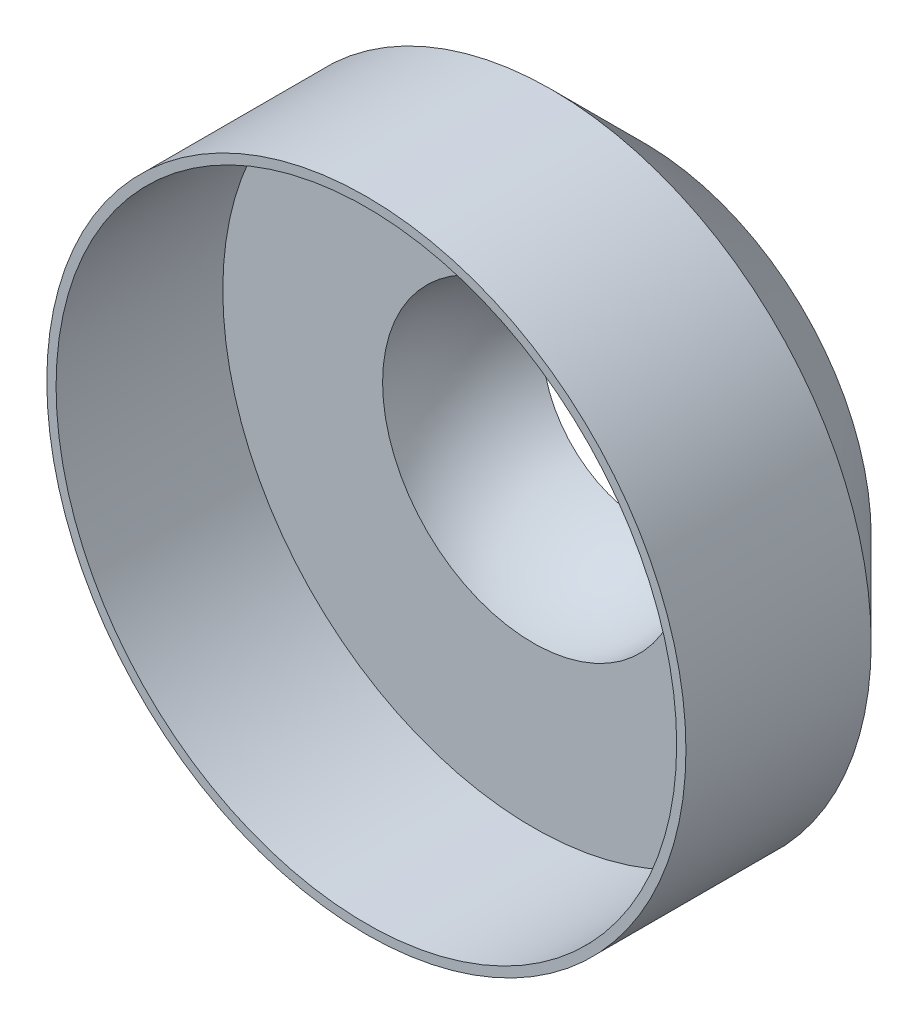
from build123d import *

# Parameters (mm, degrees)
SKETCH1_R           = 34.5
BOSS_EXTRUDE1_DEPTH = 30
SKETCH5_R           = 33.5
CUT_EXTRUDE2_DEPTH  = 18
CUT_REVOLVE3_ANGLE  = 180
CHAMFER1_SIZE       = 10


with BuildPart() as part:
    # Sketch1 → Boss-Extrude1 (new body)
    with BuildSketch(Plane.XY):
        Circle(SKETCH1_R)
    extrude(amount=BOSS_EXTRUDE1_DEPTH)

    # Sketch5 → Cut-Extrude2 (cut)
    with BuildSketch(Plane.XY.offset(30)):
        Circle(SKETCH5_R)
    extrude(amount=-CUT_EXTRUDE2_DEPTH, mode=Mode.SUBTRACT)

    # Sketch7 → Cut-Revolve3 (revolve, cut)
    with BuildSketch(Plane.XY.offset(12)):
        with BuildLine():
            Line((-16.25, 0), (16.25, 0))
            ThreePointArc((16.25, 0), (0, 16.25), (-16.25, 0))
        make_face()
    revolve(axis=Axis((-16.25, 0, 12), (-1, 0, 0)), revolution_arc=CUT_REVOLVE3_ANGLE, mode=Mode.SUBTRACT)

    # Chamfer1
    chamfer1_edges = [part.edges().sort_by_distance(p)[0] for p in [
        (-34.5, 0, 0),
    ]]
    chamfer(chamfer1_edges, length=CHAMFER1_SIZE)


solid = part.part
